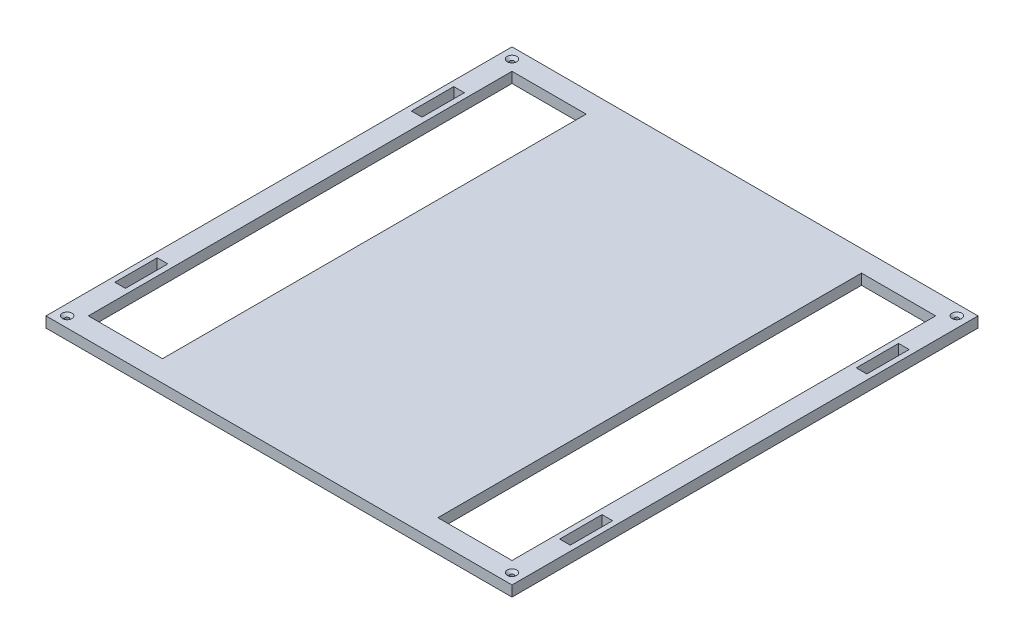
from build123d import *

# Parameters (mm, degrees)
SKETCH1_W                       = 279.4
SKETCH1_H                       = 279.4
BOSS_EXTRUDE1_DEPTH             = 6.35
SKETCH2_W                       = 44.45
SKETCH2_H                       = 254
SKETCH2_W_2                     = 6.35
SKETCH2_H_2                     = 25.4
CUT_EXTRUDE1_DEPTH              = 7.35
F_4_40_TAPPED_HOLE1_D           = 2.2606
F_4_40_TAPPED_HOLE1_CSINK_D     = 5.715
F_4_40_TAPPED_HOLE1_CSINK_ANGLE = 100


with BuildPart() as part:
    # Sketch1 → Boss-Extrude1 (new body)
    with BuildSketch(Plane(origin=(0, 0, 0), x_dir=(1, 0, 0), z_dir=(0, 1, 0))):
        Rectangle(SKETCH1_W, SKETCH1_H)
    extrude(amount=BOSS_EXTRUDE1_DEPTH)

    # Sketch2 → Cut-Extrude1 (cut, through all)
    with BuildSketch(Plane(origin=(0, 6.35, 0), x_dir=(1, 0, 0), z_dir=(0, 1, 0))):
        with Locations((-104.775, 0)):
            Rectangle(SKETCH2_W, SKETCH2_H)
        with Locations((104.775, 0)):
            Rectangle(SKETCH2_W, SKETCH2_H)
        with Locations((133.35, 88.9)):
            Rectangle(SKETCH2_W_2, SKETCH2_H_2)
        with Locations((-133.35, 88.9)):
            Rectangle(SKETCH2_W_2, SKETCH2_H_2)
        with Locations((133.35, -88.9)):
            Rectangle(SKETCH2_W_2, SKETCH2_H_2)
        with Locations((-133.35, -88.9)):
            Rectangle(SKETCH2_W_2, SKETCH2_H_2)
    extrude(amount=-CUT_EXTRUDE1_DEPTH, mode=Mode.SUBTRACT)

    # #4-40 Tapped Hole1 (through all)
    with Locations(Plane(origin=(0, 6.35, 0), x_dir=(1, 0, 0), z_dir=(0, 1, 0))):
        with Locations((-133.35, 133.35), (-133.35, -133.35), (133.35, -133.35), (133.35, 133.35)):
            CounterSinkHole(F_4_40_TAPPED_HOLE1_D / 2, F_4_40_TAPPED_HOLE1_CSINK_D / 2, counter_sink_angle=F_4_40_TAPPED_HOLE1_CSINK_ANGLE)


solid = part.part
